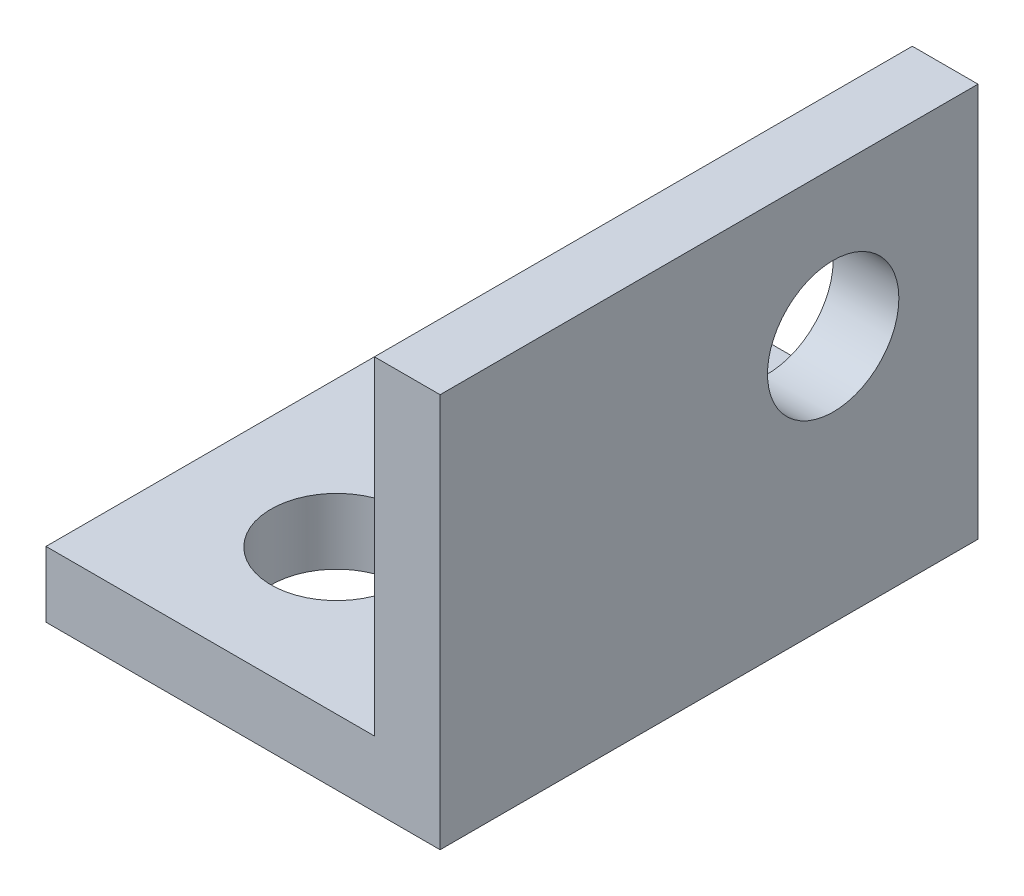
from build123d import *

# Parameters (mm, degrees)
BOSS_EXTRUDE1_DEPTH = 6.5
SKETCH4_R           = 1.5875
CUT_EXTRUDE1_DEPTH  = 10
SKETCH5_R           = 1.5875
CUT_EXTRUDE2_DEPTH  = 10


with BuildPart() as part:
    # Sketch3 → Boss-Extrude1 (new body, symmetric)
    with BuildSketch(Plane.XY):
        Polygon((3.175, -3.175), (-4.7625, -3.175), (-4.7625, -4.7625), (4.7625, -4.7625), (4.7625, 4.7625), (3.175, 4.7625), align=None)
    extrude(amount=BOSS_EXTRUDE1_DEPTH, both=True)

    # Sketch4 → Cut-Extrude1 (cut)
    with BuildSketch(Plane(origin=(4.7625, 0, 0), x_dir=(0, 0, -1), z_dir=(1, 0, 0))):
        with Locations((3, 1.2375)):
            Circle(SKETCH4_R)
    extrude(amount=-CUT_EXTRUDE1_DEPTH, mode=Mode.SUBTRACT)

    # Sketch5 → Cut-Extrude2 (cut)
    with BuildSketch(Plane.XZ.offset(4.7625)):
        with Locations((-1.2375, 3)):
            Circle(SKETCH5_R)
    extrude(amount=-CUT_EXTRUDE2_DEPTH, mode=Mode.SUBTRACT)


solid = part.part
